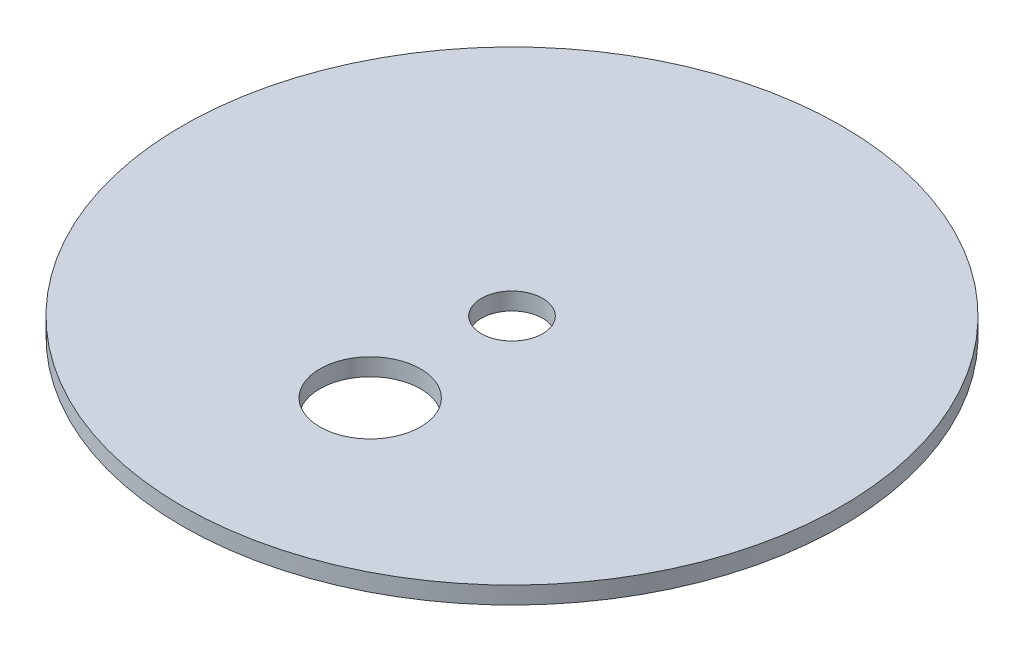
from build123d import *

# Parameters (mm, degrees)
SKETCH1_R               = 57.15
BOSS_EXTRUDE1_DEPTH     = 3
SKETCH2_R               = 5.315503086
SKETCH2_R_2             = 8.729677968
CUT_EXTRUDE2_DEPTH      = 13
CUT_EXTRUDE2_DEPTH_BACK = 3


with BuildPart() as part:
    # Sketch1 → Boss-Extrude1 (new body)
    with BuildSketch(Plane(origin=(0, 0, 0), x_dir=(1, 0, 0), z_dir=(0, 1, 0))):
        Circle(SKETCH1_R)
    extrude(amount=BOSS_EXTRUDE1_DEPTH)

    # Sketch2 → Cut-Extrude2 (cut, two sides)
    with BuildSketch(Plane(origin=(0, 0, 0), x_dir=(1, 0, 0), z_dir=(0, 1, 0))) as cut_extrude2_sk:
        Circle(SKETCH2_R)
        with Locations((0, -24.58879827)):
            Circle(SKETCH2_R_2)
    extrude(amount=CUT_EXTRUDE2_DEPTH, mode=Mode.SUBTRACT)
    extrude(cut_extrude2_sk.sketch, amount=-CUT_EXTRUDE2_DEPTH_BACK, mode=Mode.SUBTRACT)


solid = part.part
